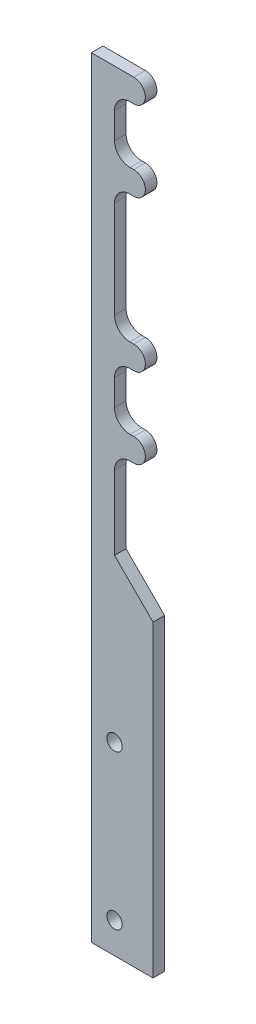
from build123d import *

# Parameters (mm, degrees)
SKETCH1_R           = 1.5
BOSS_EXTRUDE1_DEPTH = 1.5
FILLET1_R           = 2
SKETCH2_R           = 1
CUT_EXTRUDE1_DEPTH  = 5


with BuildPart() as part:
    # Sketch1 → Boss-Extrude1 (new body)
    with BuildSketch(Plane.XY):
        with BuildLine():
            Line((-5.5, -11.303847577), (-3, -11.303847577))
            ThreePointArc((-3, -11.303847577), (-4.5, -9.803847577), (-3, -8.303847577))
            Line((-3, -8.303847577), (-8.5, -8.303847577))
            Line((-8.5, -8.303847577), (-8.5, -108.303847577))
            Line((-8.5, -108.303847577), (-0.5, -108.303847577))
            Line((-0.5, -108.303847577), (-0.5, -68.303847577))
            Line((-0.5, -68.303847577), (-5.5, -63.303847577))
            Line((-5.5, -63.303847577), (-5.5, -51.696152423))
            Line((-5.5, -51.696152423), (-3, -51.696152423))
            ThreePointArc((-3, -51.696152423), (-4.5, -50.196152423), (-3, -48.696152423))
            Line((-3, -48.696152423), (-5.5, -48.696152423))
            Line((-5.5, -48.696152423), (-5.5, -41.303847577))
            Line((-5.5, -41.303847577), (-3, -41.303847577))
            ThreePointArc((-3, -41.303847577), (-4.5, -39.803847577), (-3, -38.303847577))
            Line((-3, -38.303847577), (-5.5, -38.303847577))
            Line((-5.5, -38.303847577), (-5.5, -21.696152423))
            Line((-5.5, -21.696152423), (-3, -21.696152423))
            ThreePointArc((-3, -21.696152423), (-4.5, -20.196152423), (-3, -18.696152423))
            Line((-3, -18.696152423), (-5.5, -18.696152423))
            Line((-5.5, -18.696152423), (-5.5, -11.303847577))
        make_face()
        with Locations((-3, -39.803847577)):
            Circle(SKETCH1_R)
        with Locations((-3, -50.196152423)):
            Circle(SKETCH1_R)
        with Locations((-3, -9.803847577)):
            Circle(SKETCH1_R)
        with Locations((-3, -20.196152423)):
            Circle(SKETCH1_R)
    extrude(amount=BOSS_EXTRUDE1_DEPTH)

    # Fillet1
    fillet1_edges = [part.edges().sort_by_distance(p)[0] for p in [
        (-5.5, -51.696152423, 0.75),
        (-5.5, -11.303847577, 0.75),
        (-5.5, -18.696152423, 0.75),
        (-5.5, -21.696152423, 0.75),
        (-5.5, -38.303847577, 0.75),
        (-5.5, -41.303847577, 0.75),
        (-5.5, -48.696152423, 0.75),
    ]]
    fillet(fillet1_edges, radius=FILLET1_R)

    # Sketch2 → Cut-Extrude1 (cut)
    with BuildSketch(Plane.XY.offset(1.5)):
        with Locations((-5.5, -104.303847577)):
            Circle(SKETCH2_R)
        with Locations((-5.5, -84.303847577)):
            Circle(SKETCH2_R)
    extrude(amount=-CUT_EXTRUDE1_DEPTH, mode=Mode.SUBTRACT)


solid = part.part
